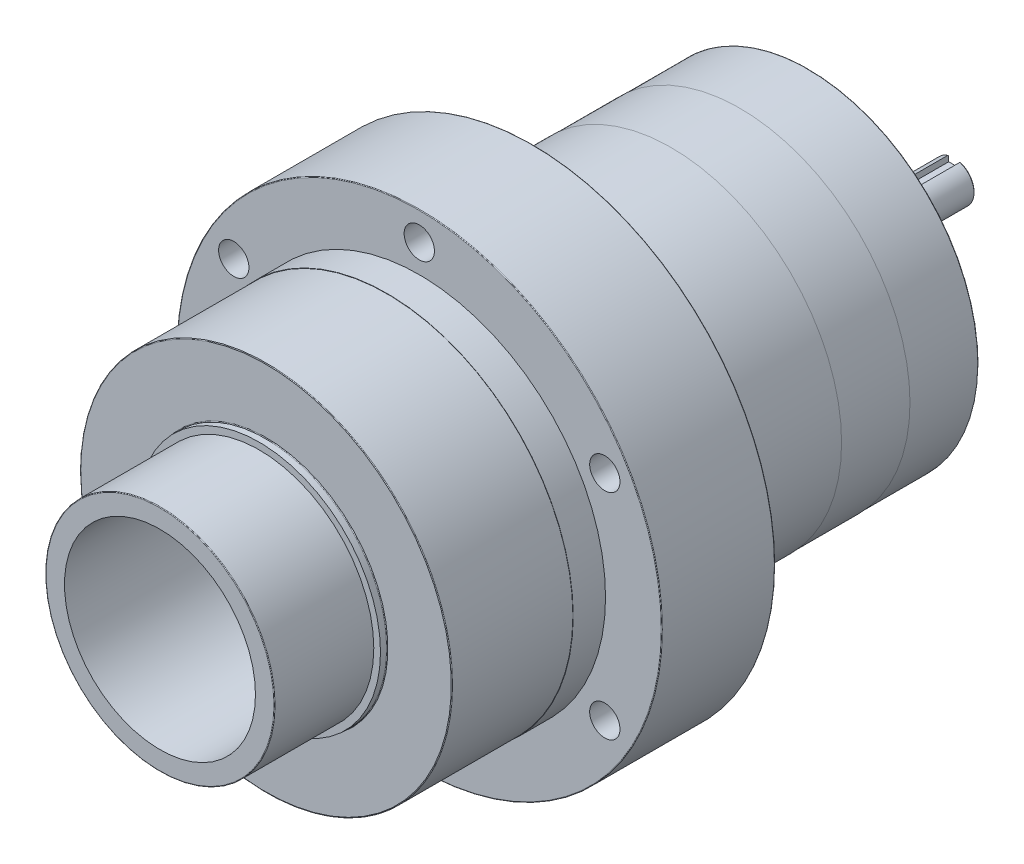
from build123d import *

# Parameters (mm, degrees)
SKETCH1_R                 = 47.625
EXTRUDE_E_DEPTH           = 41.656
SKETCH2_R                 = 47.625
SKETCH2_R_2               = 44.9961
FROM_DRAWING_DEPTH        = 38.989
SKETCH3_R                 = 73.025
EXTRUDE_C_DEPTH           = 60.198
SKETCH4_R                 = 73.152
SKETCH4_R_2               = 73.025
BOSS_EXTRUDE3_DEPTH       = 12.7
SKETCH5_R                 = 95.25
EXTRUDE_B_DEPTH           = 44.45
CUT_EXTRUDE_START         = -101.6
SKETCH6_R                 = 37.5031
CUT_EXTRUDE_F_DEPTH       = 101.6
SKETCH8_R                 = 66.675
EXTRUDE_D_DEPTH           = 108.458
BOSS_EXTRUDE6_START       = 26.9875
SKETCH9_R                 = 66.802
BOSS_EXTRUDE6_DEPTH       = 26.9875
SKETCH10_R                = 66.929
BOSS_EXTRUDE7_DEPTH       = 54.483
SKETCH11_R                = 27.813
FROM_DRAWING_2_DEPTH      = 7.9248
SKETCH12_R                = 24.9936
EXTRUDE_Q_DEPTH           = 17.526
SKETCH13_R                = 7.9375
EXTRUDE_R_DEPTH           = 31.9532
HOLE_WIZARD_S_D           = 11.90498
HOLE_WIZARD_S_CBORE_D     = 18.25752
HOLE_WIZARD_S_CBORE_DEPTH = 11.1125
CIRPATTERN1_COUNT         = 6
SKETCH16_R                = 19.05
SKETCH16_R_2              = 7.9375
FROM_DRAWING_3_DEPTH      = 14.224
CUT_EXTRUDE_T_REACH       = 92.056
CUT_EXTRUDE_T_END_RADIUS  = 7.9375
CHAMFER1_SIZE             = 0.381
FILLET1_R                 = 0.254


with BuildPart() as part:
    # Sketch1 → Extrude E (new body)
    with BuildSketch(Plane.XY):
        Circle(SKETCH1_R)
    extrude(amount=-EXTRUDE_E_DEPTH)

    # Sketch2 → from drawing (cut)
    with BuildSketch(Plane.XY):
        Circle(SKETCH2_R)
        Circle(SKETCH2_R_2, mode=Mode.SUBTRACT)
    extrude(amount=-FROM_DRAWING_DEPTH, mode=Mode.SUBTRACT)

    # Sketch3 → Extrude C (add)
    with BuildSketch(Plane(origin=(0, 0, -41.656), x_dir=(-1, 0, 0), z_dir=(0, 0, -1))):
        with Locations(Location((0, 0, 0), (0, 0, 180))):  # turned: the seam where the file's is
            Circle(SKETCH3_R)
    extrude(amount=EXTRUDE_C_DEPTH)

    # Sketch4 → Boss-Extrude3 (add)
    with BuildSketch(Plane.XY.offset(-89.154)):
        Circle(SKETCH4_R)
        Circle(SKETCH4_R_2, mode=Mode.SUBTRACT)
    extrude(amount=-BOSS_EXTRUDE3_DEPTH)

    # Sketch5 → Extrude B (add)
    with BuildSketch(Plane.XY.offset(-101.854)):
        Circle(SKETCH5_R)
    extrude(amount=-EXTRUDE_B_DEPTH)

    # Sketch6 → Cut-Extrude F (cut)
    with BuildSketch(Plane.XY.offset(CUT_EXTRUDE_START)):
        Circle(SKETCH6_R)
    extrude(amount=CUT_EXTRUDE_F_DEPTH, mode=Mode.SUBTRACT)

    # Sketch8 → Extrude D (add)
    with BuildSketch(Plane(origin=(0, 0, -146.304), x_dir=(-1, 0, 0), z_dir=(0, 0, -1))):
        with Locations(Location((0, 0, 0), (0, 0, 180))):  # turned: the seam where the file's is
            Circle(SKETCH8_R)
    extrude(amount=EXTRUDE_D_DEPTH)

    # Sketch9 → Boss-Extrude6 (add)
    with BuildSketch(Plane.XY.offset(-254.762).offset(BOSS_EXTRUDE6_START)):
        Circle(SKETCH9_R)
    extrude(amount=BOSS_EXTRUDE6_DEPTH)

    # Sketch10 → Boss-Extrude7 (add)
    with BuildSketch(Plane.XY.offset(-200.787)):
        Circle(SKETCH10_R)
    extrude(amount=BOSS_EXTRUDE7_DEPTH)

    # Sketch11 → from drawing 2 (add)
    with BuildSketch(Plane(origin=(0, 0, -254.762), x_dir=(-1, 0, 0), z_dir=(0, 0, -1))):
        with Locations(Location((0, 0, 0), (0, 0, 180))):  # turned: the seam where the file's is
            Circle(SKETCH11_R)
    extrude(amount=FROM_DRAWING_2_DEPTH)

    # Sketch12 → Extrude Q (add)
    with BuildSketch(Plane(origin=(0, 0, -262.6868), x_dir=(-1, 0, 0), z_dir=(0, 0, -1))):
        with Locations(Location((0, 0, 0), (0, 0, 180))):  # turned: the seam where the file's is
            Circle(SKETCH12_R)
    extrude(amount=EXTRUDE_Q_DEPTH)

    # Sketch13 → Extrude R (add)
    with BuildSketch(Plane(origin=(0, 0, -280.2128), x_dir=(-1, 0, 0), z_dir=(0, 0, -1))):
        with Locations(Location((0, 0, 0), (0, 0, 180))):  # turned: the seam where the file's is
            Circle(SKETCH13_R)
    extrude(amount=EXTRUDE_R_DEPTH)

    # Hole Wizard S (through all)
    with Locations(Plane(origin=(0, 0, -146.304), x_dir=(-1, 0, 0), z_dir=(0, 0, -1))):
        with Locations((0, -84.1375)):
            hole_wizard_s = CounterBoreHole(HOLE_WIZARD_S_D / 2, HOLE_WIZARD_S_CBORE_D / 2, HOLE_WIZARD_S_CBORE_DEPTH)

    # CirPattern1: Hole Wizard S ×6 about axis
    cirpattern1_axis = Axis((0, 0, 0), (0, 0, 1))
    for i in range(1, CIRPATTERN1_COUNT):
        add(hole_wizard_s.rotate(cirpattern1_axis, i * 360 / CIRPATTERN1_COUNT), mode=Mode.SUBTRACT)

    # Sketch16 → from drawing 3 (cut)
    with BuildSketch(Plane(origin=(0, 0, -280.2128), x_dir=(-1, 0, 0), z_dir=(0, 0, -1))):
        Circle(SKETCH16_R)
        with Locations(Location((0, 0, 0), (0, 0, 180))):  # turned: the seam where the file's is
            Circle(SKETCH16_R_2, mode=Mode.SUBTRACT)
    extrude(amount=-FROM_DRAWING_3_DEPTH, mode=Mode.SUBTRACT)

    # Cut-Extrude T: up to this cylinder (the profile starts inside it)
    cut_extrude_t_end = Plane(origin=(0, 0, -297.8785), z_dir=(0, 0, 1)) * Cylinder(CUT_EXTRUDE_T_END_RADIUS, 200.987, mode=Mode.PRIVATE)
    # Sketch17 → Cut-Extrude T (cut, up to the surface)
    with BuildSketch(Plane.XZ.offset(-5.1943), mode=Mode.PRIVATE) as cut_extrude_t_sk1:
        with BuildLine():
            Line((-2.3876, -312.166), (-2.3876, -283.591))
            ThreePointArc((-2.3876, -283.591), (0, -281.2034), (2.3876, -283.591))
            Line((2.3876, -283.591), (2.3876, -312.166))
            ThreePointArc((2.3876, -312.166), (0, -314.5536), (-2.3876, -312.166))
        make_face()
    cut_extrude_t_tool1 = extrude(cut_extrude_t_sk1.sketch, amount=-CUT_EXTRUDE_T_REACH, mode=Mode.PRIVATE) & cut_extrude_t_end
    add(cut_extrude_t_tool1.solids().sort_by_distance((0, 5.1943, -297.8785))[0], mode=Mode.SUBTRACT)

    # Chamfer1
    chamfer1_edges = [part.edges().sort_by_distance(p)[0] for p in [
        (-4.693204196, -6.401385836, -312.166),
    ]]
    chamfer(chamfer1_edges, length=CHAMFER1_SIZE)

    # Fillet1
    fillet1_edges = [part.edges().sort_by_distance(p)[0] for p in [
        (-68.300832411, -49.974488065, -146.304),
        (-44.9961, 0, 0),
        (-73.025, 0, -41.656),
        (-95.25, 0, -101.854),
        (-95.25, 0, -146.304),
        (-66.675, 0, -254.762),
        (-47.625, 0, -41.656),
        (-66.929, 0, -146.304),
        (-27.813, 0, -254.762),
        (-27.813, 0, -262.6868),
        (-24.9936, 0, -262.6868),
        (-24.9936, 0, -280.2128),
        (9.12876, -84.1375, -146.304),
        (77.429592411, -34.163011935, -146.304),
        (68.300832411, 49.974488065, -146.304),
        (-9.12876, 84.1375, -146.304),
        (-77.429592411, 34.163011935, -146.304),
    ]]
    fillet(fillet1_edges, radius=FILLET1_R)


solid = part.part
